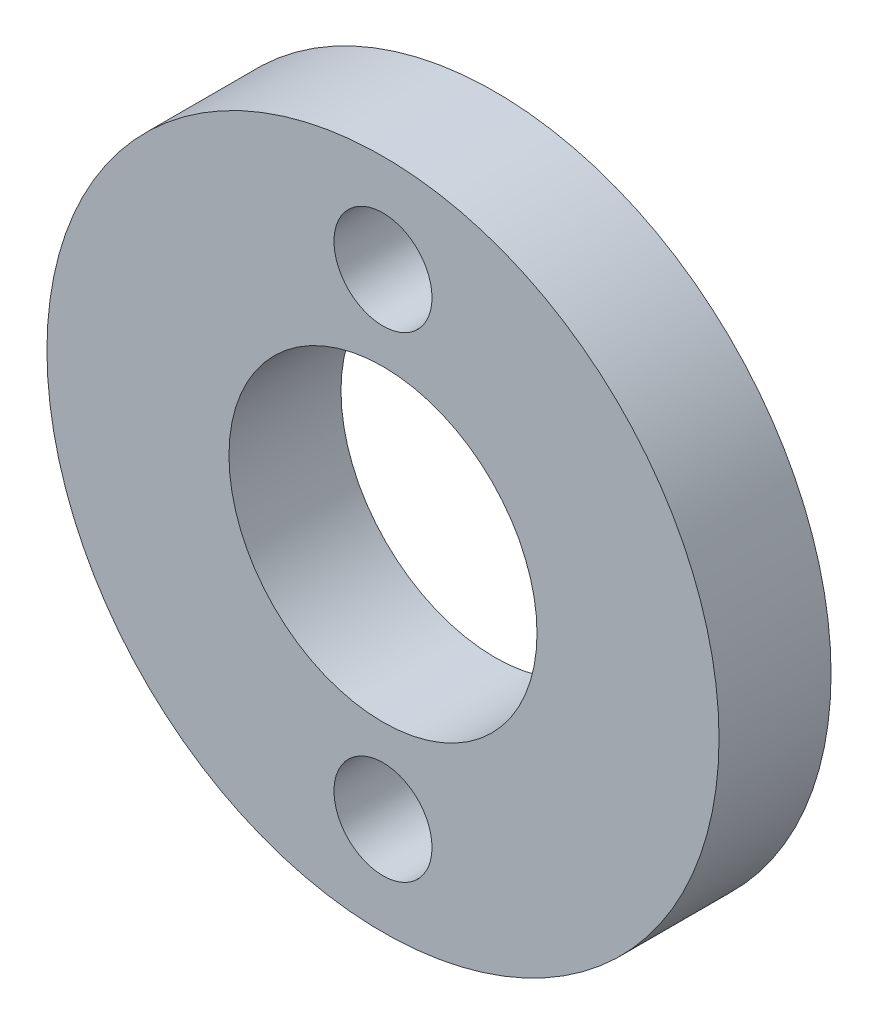
from build123d import *

# Parameters (mm, degrees)
SKETCH_1_R      = 12
SKETCH_1_R_2    = 5.5
SKETCH_1_R_3    = 1.75
EXTRUDE_1_DEPTH = 4


with BuildPart() as part:
    # Эскиз1 → Бобышка-Вытянуть1 (new body)
    with BuildSketch(Plane.XY):
        Circle(SKETCH_1_R)
        Circle(SKETCH_1_R_2, mode=Mode.SUBTRACT)
        with Locations((0, 8.5)):
            Circle(SKETCH_1_R_3, mode=Mode.SUBTRACT)
        with Locations((0, -8.5)):
            Circle(SKETCH_1_R_3, mode=Mode.SUBTRACT)
    extrude(amount=EXTRUDE_1_DEPTH)


solid = part.part
